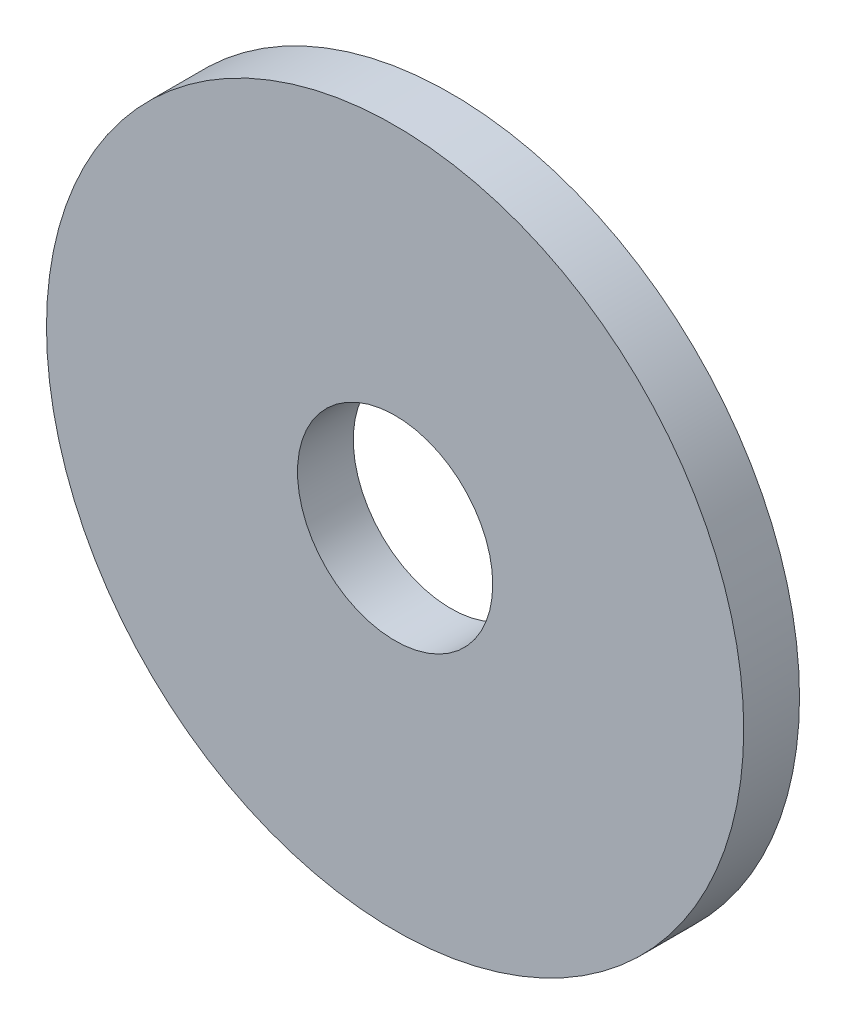
from build123d import *

# Parameters (mm, degrees)
ESQUISSE1_R          = 12.5
ESQUISSE1_R_2        = 3.5
BASE_EXTRUSION_DEPTH = 2


with BuildPart() as part:
    # Esquisse1 → Base-Extrusion (new body)
    with BuildSketch(Plane.XY):
        Circle(ESQUISSE1_R)
        Circle(ESQUISSE1_R_2, mode=Mode.SUBTRACT)
    extrude(amount=BASE_EXTRUSION_DEPTH)


solid = part.part
